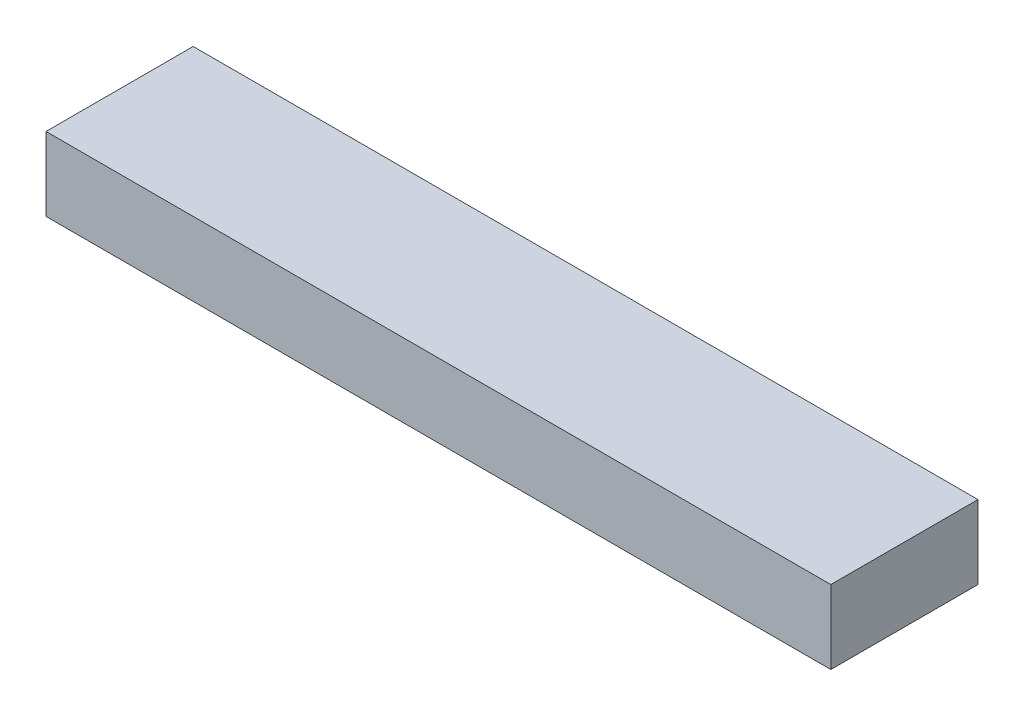
from build123d import *

# Parameters (mm, degrees)
SKETCH1_W           = 541.7304126
SKETCH1_H           = 101.6
BOSS_EXTRUDE1_DEPTH = 50.8


with BuildPart() as part:
    # Sketch1 → Boss-Extrude1 (new body)
    with BuildSketch(Plane(origin=(0, 0, 0), x_dir=(1, 0, 0), z_dir=(0, 1, 0))):
        Rectangle(SKETCH1_W, SKETCH1_H)
    extrude(amount=BOSS_EXTRUDE1_DEPTH)


solid = part.part
